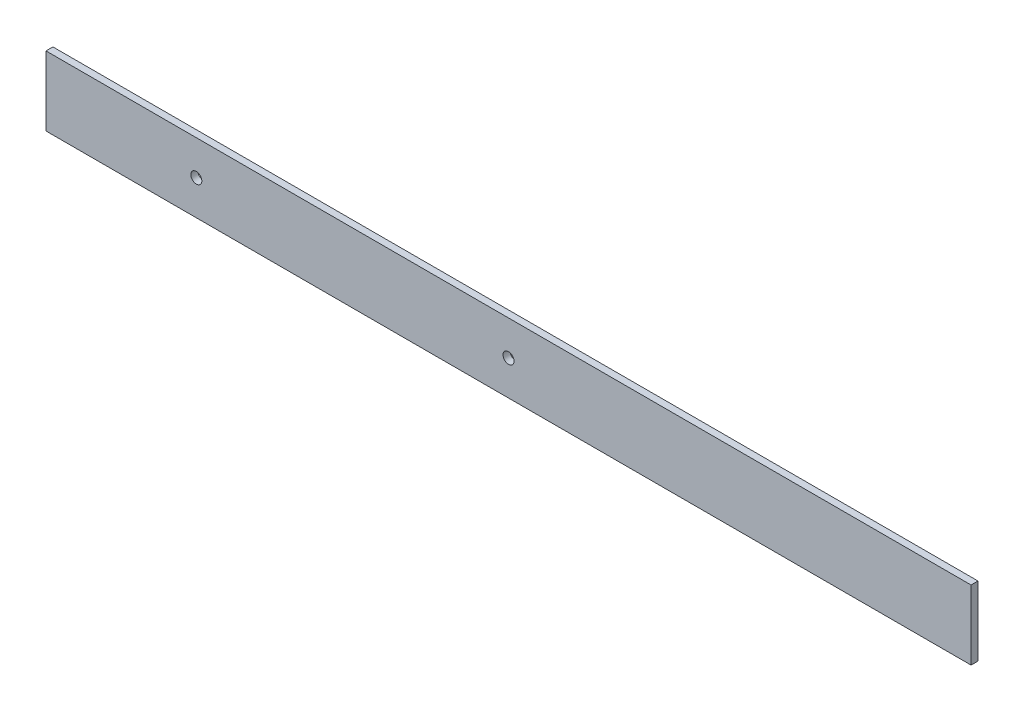
from build123d import *

# Parameters (mm, degrees)
CROQUIS1_W              = 400
CROQUIS1_H              = 30
CROQUIS1_R              = 2.38125
SALIENTE_EXTRUIR1_DEPTH = 3
CROQUIS2_R              = 2.38125
CORTAR_EXTRUIR2_DEPTH   = 4


with BuildPart() as part:
    # Croquis1 → Saliente-Extruir1 (new body)
    with BuildSketch(Plane.XY):
        Rectangle(CROQUIS1_W, CROQUIS1_H)
        Circle(CROQUIS1_R, mode=Mode.SUBTRACT)
    extrude(amount=SALIENTE_EXTRUIR1_DEPTH)

    # Croquis2 → Cortar-Extruir2 (cut, through all)
    with BuildSketch(Plane.XY):
        with Locations((-135, 0)):
            Circle(CROQUIS2_R)
    extrude(amount=CORTAR_EXTRUIR2_DEPTH, mode=Mode.SUBTRACT)


solid = part.part
